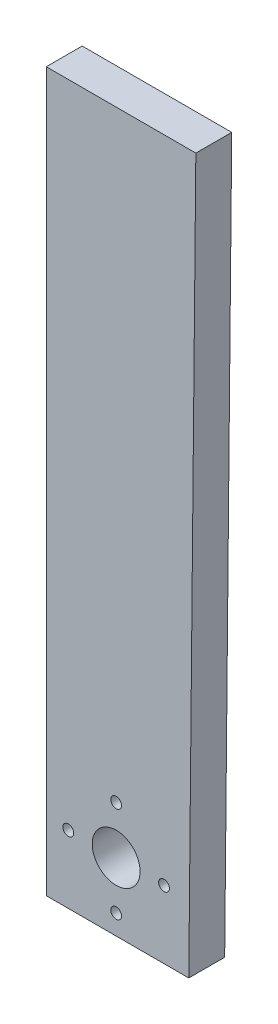
from build123d import *

# Parameters (mm, degrees)
ESQUISSE1_R        = 0.9
ESQUISSE1_R_2      = 4
BOSS_EXTRU_1_DEPTH = 6


with BuildPart() as part:
    # Esquisse1 → Boss.-Extru.1 (new body)
    with BuildSketch(Plane.XY):
        Polygon((24.982504982, -97.610209745), (24.982504982, 22.389790255), (49.982504982, 22.389790255), (48.802130714, -97.610209745), align=None)
        with Locations((28.664029602, -86.275370074)):
            Circle(ESQUISSE1_R, mode=Mode.SUBTRACT)
        with Locations((36.664029602, -78.275370074)):
            Circle(ESQUISSE1_R, mode=Mode.SUBTRACT)
        with Locations((44.664029602, -86.275370074)):
            Circle(ESQUISSE1_R, mode=Mode.SUBTRACT)
        with Locations((36.664029602, -94.275370074)):
            Circle(ESQUISSE1_R, mode=Mode.SUBTRACT)
        with Locations((36.664029602, -86.275370074)):
            Circle(ESQUISSE1_R_2, mode=Mode.SUBTRACT)
    extrude(amount=BOSS_EXTRU_1_DEPTH)


solid = part.part
